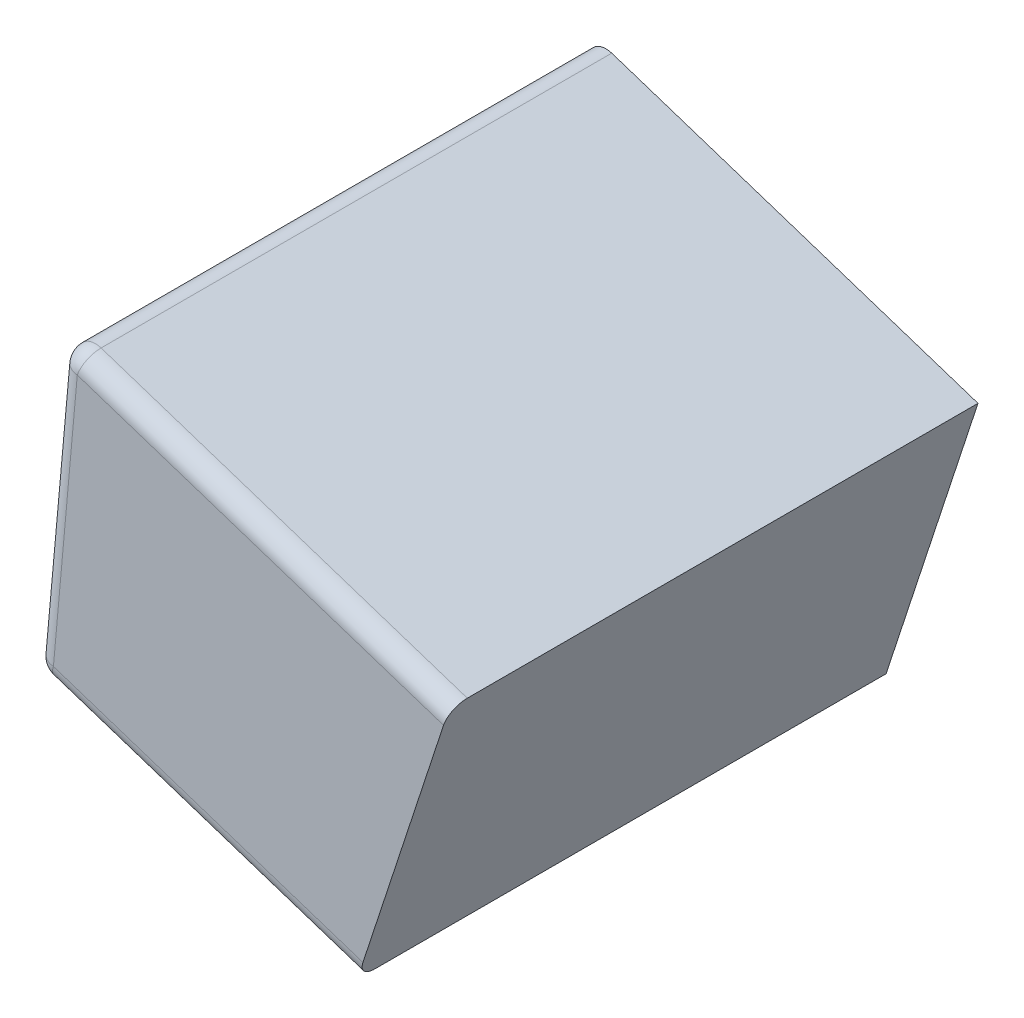
from build123d import *

# Parameters (mm, degrees)
BOSS_EXTRUDE1_DEPTH       = 74.025
FILLET1_R                 = 2.54
HOLE1_AT_2_COUNT          = 2
HOLE1_AT_2_PITCH          = 35.650433853
HOLE1_AT_3_COUNT          = 2
HOLE1_AT_3_PITCH          = 37.7542539
HOLE1_AT_4_COUNT          = 2
HOLE1_AT_4_PITCH          = 22.225
F_8_CLEARANCE_HOLE1_D     = 4.9149
F_8_CLEARANCE_HOLE1_DEPTH = 12.7
F_8_CLEARANCE_HOLE1_TIP   = 1.476584928


with BuildPart() as part:
    # Sketch1 → Boss-Extrude1 (new body)
    with BuildSketch(Plane.XY):
        Polygon((277.604402796, 374.816405204), (281.415155825, 417.005352091), (335.71810759, 399.192100573), (322.852981494, 359.973302076), align=None)
    extrude(amount=BOSS_EXTRUDE1_DEPTH)

    # Fillet1
    fillet1_edges = [part.edges().sort_by_distance(p)[0] for p in [
        (281.415155825, 417.005352091, 37.0125),
        (279.509779311, 395.910878647, 74.025),
        (300.228692145, 367.39485364, 74.025),
        (308.566631708, 408.098726332, 74.025),
        (277.604402796, 374.816405204, 37.0125),
    ]]
    fillet(fillet1_edges, radius=FILLET1_R)

    # Sketch3 → Hole1 (revolve, cut)
    with BuildSketch(Plane(origin=(323.698740376, 393.110483865, 0), x_dir=(0, 1, 0), z_dir=(1, 0, 0))):
        Polygon((0, 0), (0, 4.699), (2.8702, 4.699), (2.9972, 0), align=None)
    hole1 = revolve(axis=Axis((323.698740376, 393.110483865, 110), (0, 0, -1)), mode=Mode.SUBTRACT)

    # Hole1 at 2: Hole1 ×2
    with Locations(*[Vector(-0.950182883, 0.31169294, 0) * (i * HOLE1_AT_2_PITCH) for i in range(1, HOLE1_AT_2_COUNT)]):
        add(hole1, mode=Mode.SUBTRACT)

    # Hole1 at 3: Hole1 ×2
    with Locations(*[Vector(-0.951584848, -0.307386202, 0) * (i * HOLE1_AT_3_PITCH) for i in range(1, HOLE1_AT_3_COUNT)]):
        add(hole1, mode=Mode.SUBTRACT)

    # Hole1 at 4: Hole1 ×2
    with Locations(*[Vector(-0.31169294, -0.950182883, 0) * (i * HOLE1_AT_4_PITCH) for i in range(1, HOLE1_AT_4_COUNT)]):
        add(hole1, mode=Mode.SUBTRACT)

    # #8 Clearance Hole1
    with Locations(Plane(origin=(0, 0, 0), x_dir=(-1, 0, 0), z_dir=(0, 0, -1))):
        with Locations((-323.698740376, 393.110483865), (-289.824308357, 404.222472403), (-287.772364418, 381.505347156), (-316.771364786, 371.99266929)):
            Hole(F_8_CLEARANCE_HOLE1_D / 2, depth=F_8_CLEARANCE_HOLE1_DEPTH)
            with Locations((0, 0, -(F_8_CLEARANCE_HOLE1_DEPTH + F_8_CLEARANCE_HOLE1_TIP / 2))):  # 118° drill point
                Cone(0, F_8_CLEARANCE_HOLE1_D / 2, F_8_CLEARANCE_HOLE1_TIP, mode=Mode.SUBTRACT)


solid = part.part
